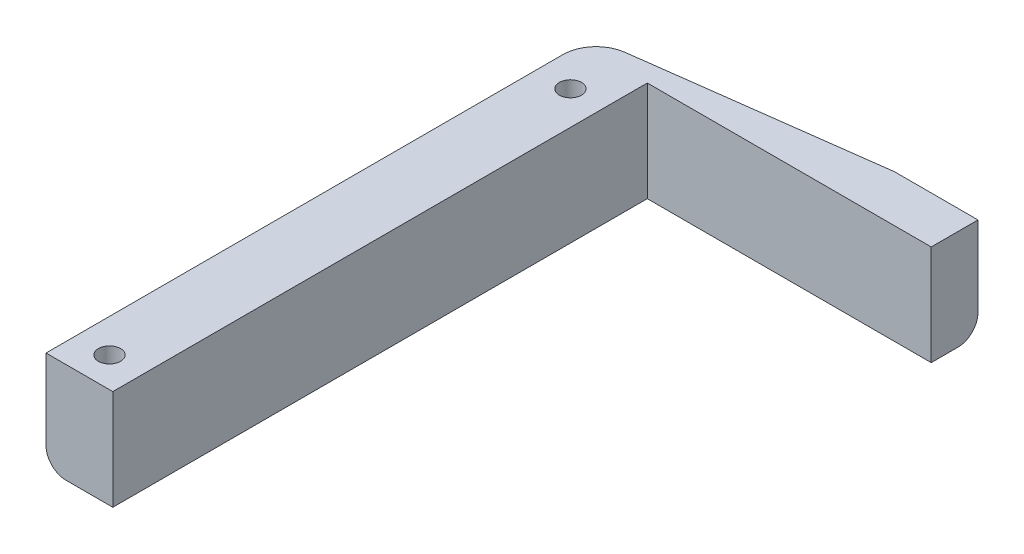
from build123d import *

# Parameters (mm, degrees)
SKETCH1_R           = 1.66
BOSS_EXTRUDE1_DEPTH = 15
CHAMFER1_SIZE       = 40
CHAMFER1_SIZE2      = 5.266099903
FILLET1_R           = 5
FILLET2_R           = 3


with BuildPart() as part:
    # Sketch1 → Boss-Extrude1 (new body)
    with BuildSketch(Plane(origin=(0, 0, 0), x_dir=(1, 0, 0), z_dir=(0, 1, 0))):
        Polygon((-40.27740406, 58.046693319), (-40.27740406, -28.953306681), (-30.27740406, -28.953306681), (-30.27740406, 51.046693319), (12.22259594, 51.046693319), (12.22259594, 58.046693319), align=None)
        with Locations(Location((-35.27740406, -24.453306681, 0), (0, 0, 270))):  # turned: the seam where the file's is
            Circle(SKETCH1_R, mode=Mode.SUBTRACT)
        with Locations(Location((-35.27740406, 44.546693319, 0), (0, 0, 270))):  # turned: the seam where the file's is
            Circle(SKETCH1_R, mode=Mode.SUBTRACT)
    extrude(amount=BOSS_EXTRUDE1_DEPTH)

    # Chamfer1
    chamfer1_edges = [part.edges().sort_by_distance(p)[0] for p in [
        (-40.27740406, 7.5, -58.046693319),
    ]]
    chamfer1_side = [part.faces().sort_by_distance(p)[0] for p in [
        (-14.02740406, 7.5, -58.046693319),
    ]]
    chamfer(chamfer1_edges, length=CHAMFER1_SIZE, length2=CHAMFER1_SIZE2, reference=chamfer1_side[0])

    # Fillet1
    fillet1_edges = [part.edges().sort_by_distance(p)[0] for p in [
        (-40.27740406, 7.5, -52.780593416),
    ]]
    fillet(fillet1_edges, radius=FILLET1_R)

    # Fillet2
    fillet2_edges = [part.edges().sort_by_distance(p)[0] for p in [
        (-40.27740406, 0, -9.72120221),
        (-18.10371954, 0, -55.699814363),
        (-39.036603097, 0, -51.692440176),
        (5.97259594, 0, -58.046693319),
    ]]
    fillet(fillet2_edges, radius=FILLET2_R)


solid = part.part
